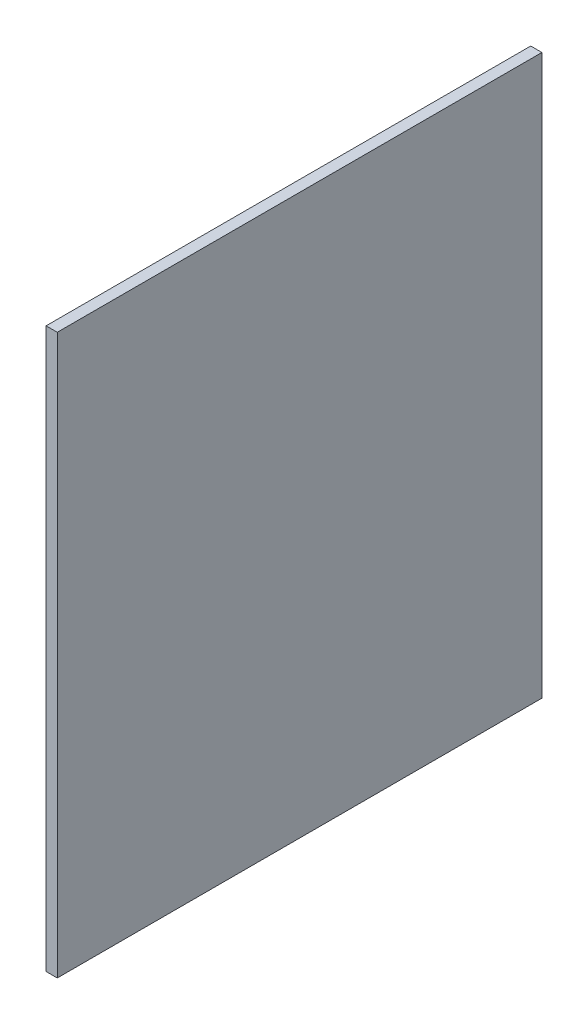
from build123d import *

# Parameters (mm, degrees)
SKETCH1_W           = 130
SKETCH1_H           = 150
BOSS_EXTRUDE1_DEPTH = 3


with BuildPart() as part:
    # Sketch1 → Boss-Extrude1 (new body)
    with BuildSketch(Plane(origin=(0, 0, 0), x_dir=(0, 0, -1), z_dir=(1, 0, 0))):
        with Locations((65, 75)):
            Rectangle(SKETCH1_W, SKETCH1_H)
    extrude(amount=BOSS_EXTRUDE1_DEPTH)


solid = part.part
